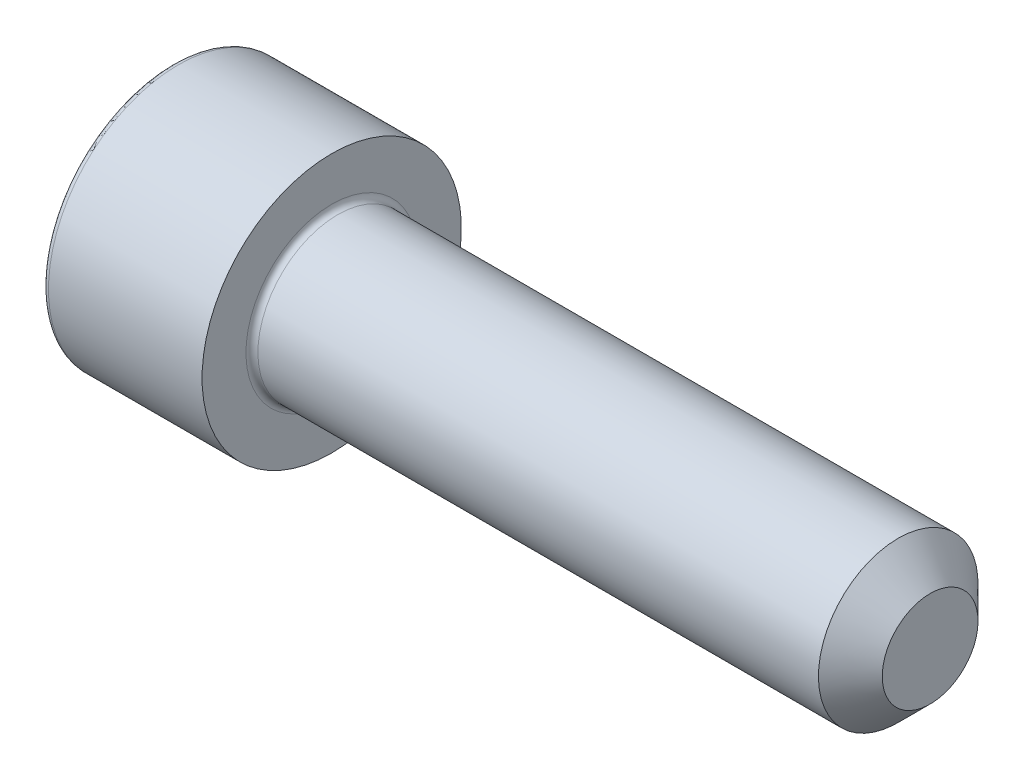
from build123d import *

# Parameters (mm, degrees)
CUT_EXTRUDE_1_DEPTH = 2.5
FILLET_1_R          = 0.3
CHAMFER_1_SIZE      = 1.6


with BuildPart() as part:
    # Эскиз1 → Повернуть1 (revolve)
    with BuildSketch(Plane.XY):
        Polygon((0, 0), (0, 6.5), (8, 6.5), (8, 4), (38, 4), (38, 0), align=None)
    revolve(axis=Axis((38, 0, 0), (-1, 0, 0)))

    # Эскиз2 → Вырез-Вытянуть1 (cut)
    with BuildSketch(Plane.ZY):
        Polygon((-1.732050808, 3), (-3.464101615, 0), (-1.732050808, -3), (1.732050808, -3), (3.464101615, 0), (1.732050808, 3), align=None)
    extrude(amount=-CUT_EXTRUDE_1_DEPTH, mode=Mode.SUBTRACT)

    # Скругление1
    fillet_1_edges = [part.edges().sort_by_distance(p)[0] for p in [
        (8, -4, 0),
        (0, -6.5, 0),
    ]]
    fillet(fillet_1_edges, radius=FILLET_1_R)

    # Фаска1
    chamfer_1_edges = [part.edges().sort_by_distance(p)[0] for p in [
        (38, -4, 0),
    ]]
    chamfer(chamfer_1_edges, length=CHAMFER_1_SIZE)


solid = part.part
